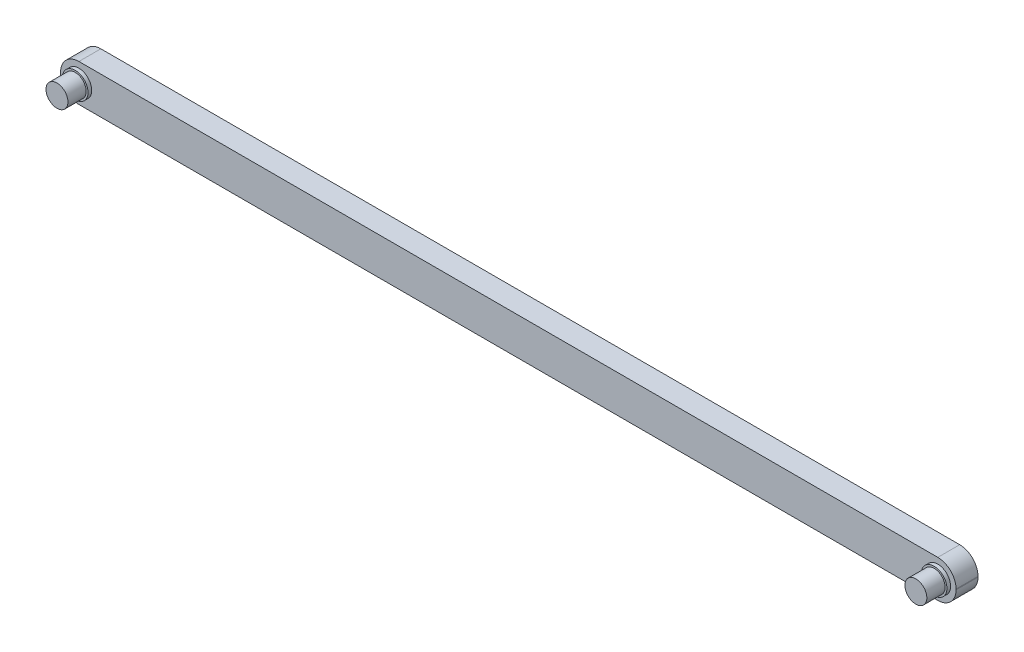
from build123d import *

# Parameters (mm, degrees)
SKETCH1_W            = 122.5
SKETCH1_H            = 10.198852772
BOSS_EXTRUDE1_DEPTH  = 6
FILLET1_R            = 5
SKETCH2_R            = 3.5
BOSS_EXTRUDE2_DEPTH  = 1
SKETCH3_R            = 3
BOSS_EXTRUDE3_DEPTH  = 5
FILLET1_OF_MIRROR1_R = 5


with BuildPart() as part:
    # Sketch1 → Boss-Extrude1 (new body)
    with BuildSketch(Plane.XY):
        Rectangle(SKETCH1_W, SKETCH1_H)
    boss_extrude1 = extrude(amount=BOSS_EXTRUDE1_DEPTH)

    # Fillet1
    fillet1_edges = [part.edges().sort_by_distance(p)[0] for p in [
        (61.25, -5.099426386, 3),
        (61.25, 5.099426386, 3),
    ]]
    fillet(fillet1_edges, radius=FILLET1_R)

    # Sketch2 → Boss-Extrude2 (add)
    with BuildSketch(Plane.XY.offset(6)):
        with Locations((56.25, 0)):
            Circle(SKETCH2_R)
    boss_extrude2 = extrude(amount=BOSS_EXTRUDE2_DEPTH)

    # Sketch3 → Boss-Extrude3 (add)
    with BuildSketch(Plane.XY.offset(7)):
        with Locations((56.25, 0)):
            Circle(SKETCH3_R)
    boss_extrude3 = extrude(amount=BOSS_EXTRUDE3_DEPTH)

    # Mirror1: Boss-Extrude1, Boss-Extrude2, Boss-Extrude3 across plane
    add(boss_extrude1.mirror(Plane(origin=(-61.25, 5.099426386, 6), x_dir=(0, 0, 1), z_dir=(1, 0, 0))))
    add(boss_extrude2.mirror(Plane(origin=(-61.25, 5.099426386, 6), x_dir=(0, 0, 1), z_dir=(1, 0, 0))))
    add(boss_extrude3.mirror(Plane(origin=(-61.25, 5.099426386, 6), x_dir=(0, 0, 1), z_dir=(1, 0, 0))))

    # Fillet1 of Mirror1
    fillet1_of_mirror1_edges = [part.edges().sort_by_distance(p)[0] for p in [
        (-183.75, -5.099426386, 3),
        (-183.75, 5.099426386, 3),
    ]]
    fillet(fillet1_of_mirror1_edges, radius=FILLET1_OF_MIRROR1_R)


solid = part.part
